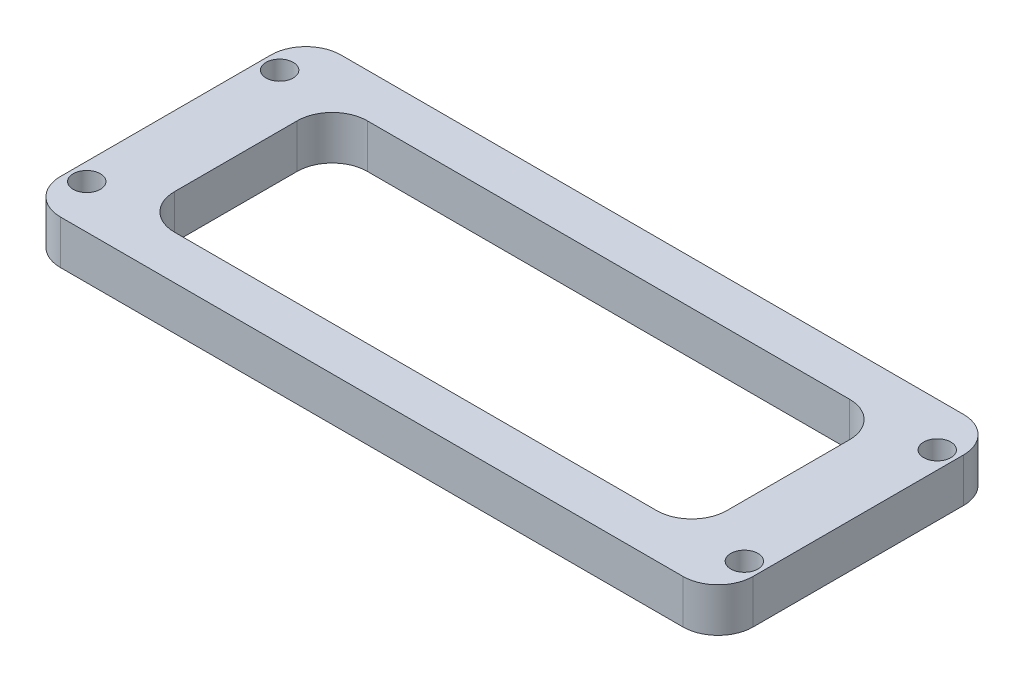
from build123d import *

# Parameters (mm, degrees)
SKETCH_1_W          = 79
SKETCH_1_H          = 32
SKETCH_1_R          = 1.55
EXTRUDE_1_DEPTH     = 5
FILLET_1_R          = 4
SKETCH_2_W          = 63
SKETCH_2_H          = 22
CUT_EXTRUDE_1_DEPTH = 6
FILLET_2_R          = 4


with BuildPart() as part:
    # 草图1 → 凸台-拉伸1 (new body)
    with BuildSketch(Plane(origin=(0, 0, 0), x_dir=(1, 0, 0), z_dir=(0, 1, 0))):
        Rectangle(SKETCH_1_W, SKETCH_1_H)
        with Locations((-37.5, 11)):
            Circle(SKETCH_1_R, mode=Mode.SUBTRACT)
        with Locations((-37.5, -11)):
            Circle(SKETCH_1_R, mode=Mode.SUBTRACT)
        with Locations((37.5, 11)):
            Circle(SKETCH_1_R, mode=Mode.SUBTRACT)
        with Locations((37.5, -11)):
            Circle(SKETCH_1_R, mode=Mode.SUBTRACT)
    extrude(amount=EXTRUDE_1_DEPTH)

    # 圆角1
    fillet_1_edges = [part.edges().sort_by_distance(p)[0] for p in [
        (39.5, 2.5, 16),
        (-39.5, 2.5, 16),
        (-39.5, 2.5, -16),
        (39.5, 2.5, -16),
    ]]
    fillet(fillet_1_edges, radius=FILLET_1_R)

    # 草图2 → 切除-拉伸1 (cut, through all)
    with BuildSketch(Plane(origin=(0, 5, 0), x_dir=(1, 0, 0), z_dir=(0, 1, 0))):
        Rectangle(SKETCH_2_W, SKETCH_2_H)
    extrude(amount=-CUT_EXTRUDE_1_DEPTH, mode=Mode.SUBTRACT)

    # 圆角2
    fillet_2_edges = [part.edges().sort_by_distance(p)[0] for p in [
        (31.5, 2.5, -11),
        (31.5, 2.5, 11),
        (-31.5, 2.5, 11),
        (-31.5, 2.5, -11),
    ]]
    fillet(fillet_2_edges, radius=FILLET_2_R)


solid = part.part
